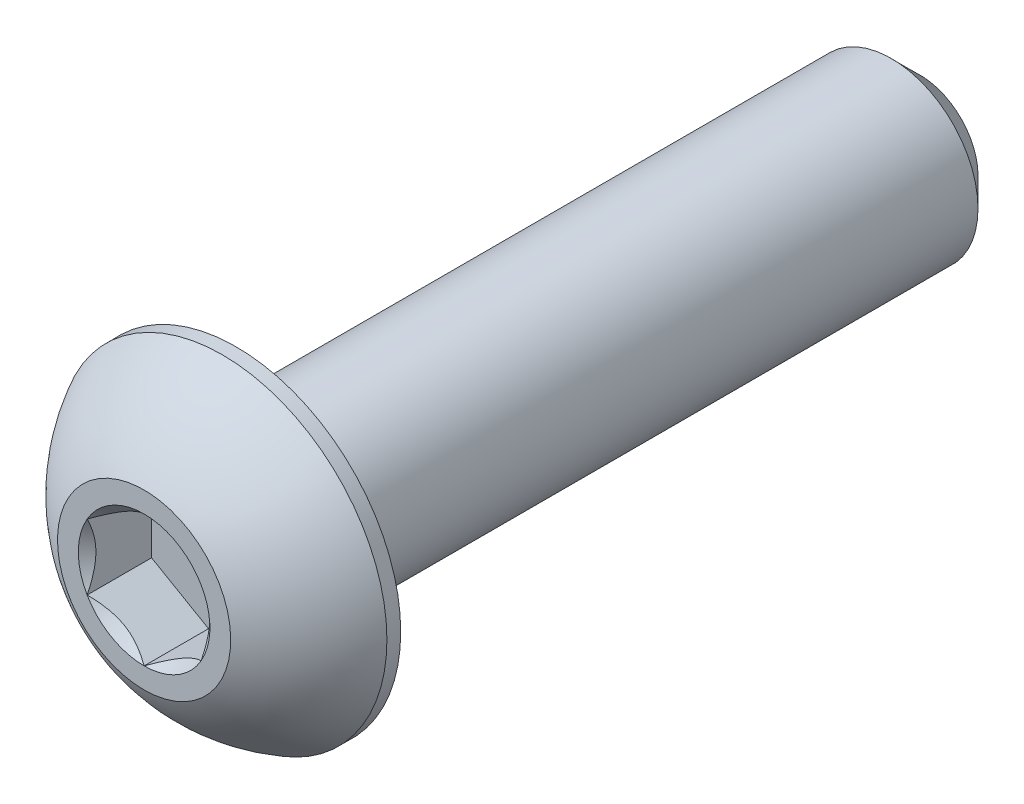
from build123d import *

# Parameters (mm, degrees)
SKETCH1_W          = 19.05
SKETCH1_H          = 2.413
CHAMFER1_SIZE      = 0.79375
CUT_EXTRUDE2_DEPTH = 1.79578
SKETCH6_R          = 1.833087105
CUT_EXTRUDE3_DEPTH = 1.79578
CUT_EXTRUDE3_TAPER = 45


with BuildPart() as part:
    # Sketch1 → Revolve1 (revolve)
    with BuildSketch(Plane(origin=(0, 0, 0), x_dir=(0, 0, -1), z_dir=(1, 0, 0))):
        with Locations((12.0904, 1.2065)):
            Rectangle(SKETCH1_W, SKETCH1_H)
    revolve(axis=Axis((0, 0, -21.6154), (0, 0, 1)))

    # Chamfer1
    chamfer1_edges = [part.edges().sort_by_distance(p)[0] for p in [
        (0, -2.413, -21.6154),
    ]]
    chamfer(chamfer1_edges, length=CHAMFER1_SIZE)

    # Sketch7 → Revolve2 (revolve)
    with BuildSketch(Plane(origin=(0, 0, 0), x_dir=(0, 0, -1), z_dir=(1, 0, 0))):
        with BuildLine():
            Line((2.18059, 4.5847), (2.5654, 4.5847))
            Line((2.5654, 4.5847), (2.5654, 0))
            Line((2.5654, 0), (0, 0))
            Line((0, 0), (0, 2.413))
            ThreePointArc((0, 2.413), (0.925030326, 3.664791196), (2.18059, 4.5847))
        make_face()
    revolve(axis=Axis((0, 0, 0), (0, 0, -1)))

    # Sketch5 → Cut-Extrude2 (cut)
    with BuildSketch(Plane.XY):
        Polygon((1.5875, -0.916543552), (1.5875, 0.916543552), (0, 1.833087105), (-1.5875, 0.916543552), (-1.5875, -0.916543552), (0, -1.833087105), align=None)
    extrude(amount=-CUT_EXTRUDE2_DEPTH, mode=Mode.SUBTRACT)

    # Sketch6 → Cut-Extrude3 (cut)
    with BuildSketch(Plane.XY):
        Circle(SKETCH6_R)
    extrude(amount=-CUT_EXTRUDE3_DEPTH, taper=CUT_EXTRUDE3_TAPER, mode=Mode.SUBTRACT)


solid = part.part
